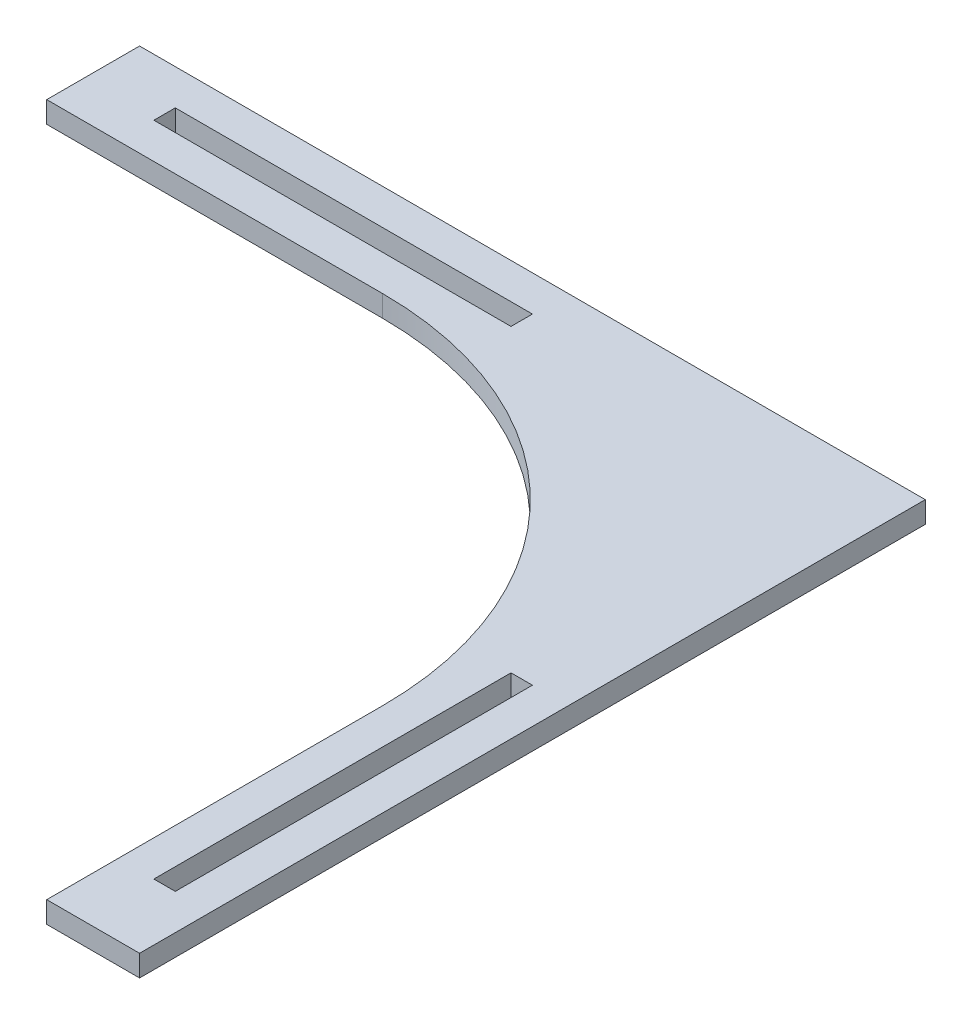
from build123d import *

# Parameters (mm, degrees)
SKETCH1_W           = 50
SKETCH1_H           = 3
SKETCH1_W_2         = 3
SKETCH1_H_2         = 50
BOSS_EXTRUDE1_DEPTH = 3


with BuildPart() as part:
    # Sketch1 → Boss-Extrude1 (new body)
    with BuildSketch(Plane(origin=(0, 0, 0), x_dir=(1, 0, 0), z_dir=(0, 1, 0))):
        with BuildLine():
            Line((-55, 55), (55, 55))
            Line((55, 55), (55, -55))
            Line((55, -55), (42, -55))
            Line((42, -55), (42, -8))
            ThreePointArc((42, -8), (27.355339059, 27.355339059), (-8, 42))
            Line((-8, 42), (-55, 42))
            Line((-55, 42), (-55, 55))
        make_face()
        with Locations((-20, 48.5)):
            Rectangle(SKETCH1_W, SKETCH1_H, mode=Mode.SUBTRACT)
        with Locations((48.5, -20)):
            Rectangle(SKETCH1_W_2, SKETCH1_H_2, mode=Mode.SUBTRACT)
    extrude(amount=BOSS_EXTRUDE1_DEPTH)


solid = part.part
